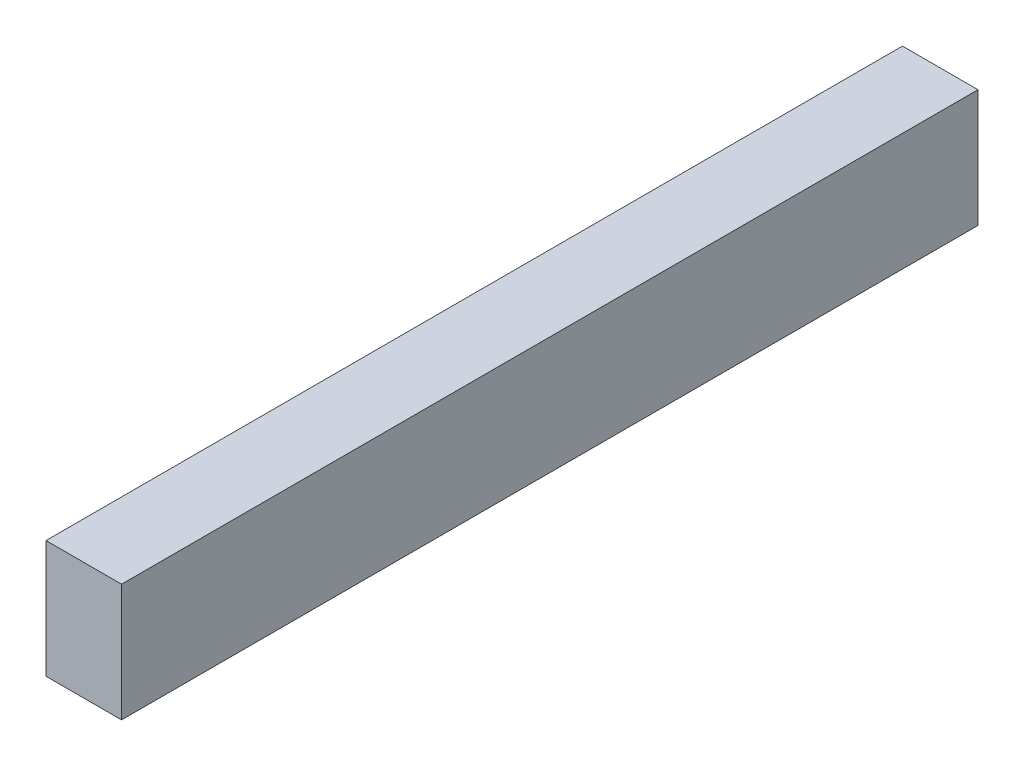
from build123d import *

# Parameters (mm, degrees)
SKETCH1_W           = 45
SKETCH1_H           = 70
BOSS_EXTRUDE1_DEPTH = 510


with BuildPart() as part:
    # Sketch1 → Boss-Extrude1 (new body)
    with BuildSketch(Plane.XY):
        with Locations((22.5, -35)):
            Rectangle(SKETCH1_W, SKETCH1_H)
    extrude(amount=BOSS_EXTRUDE1_DEPTH)


solid = part.part
